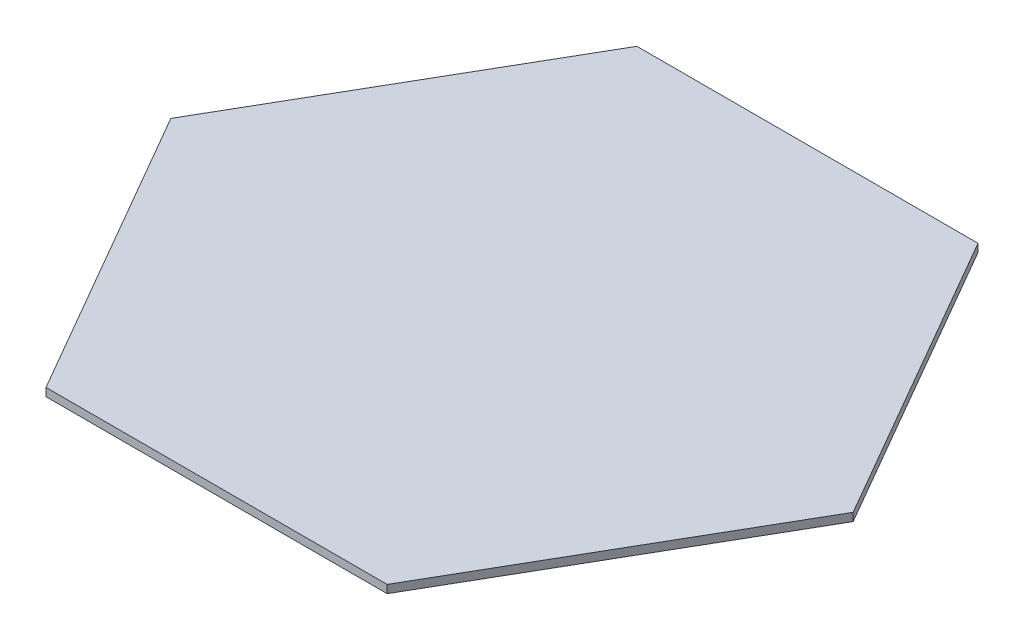
from build123d import *

# Parameters (mm, degrees)
SALIENTE_EXTRUIR1_DEPTH = 3


with BuildPart() as part:
    # Croquis1 → Saliente-Extruir1 (new body)
    with BuildSketch(Plane(origin=(0, 0, 0), x_dir=(1, 0, 0), z_dir=(0, 1, 0))):
        Polygon((63.508529611, -110), (127.017059222, 0), (63.508529611, 110), (-63.508529611, 110), (-127.017059222, 0), (-63.508529611, -110), align=None)
    extrude(amount=SALIENTE_EXTRUIR1_DEPTH)


solid = part.part
